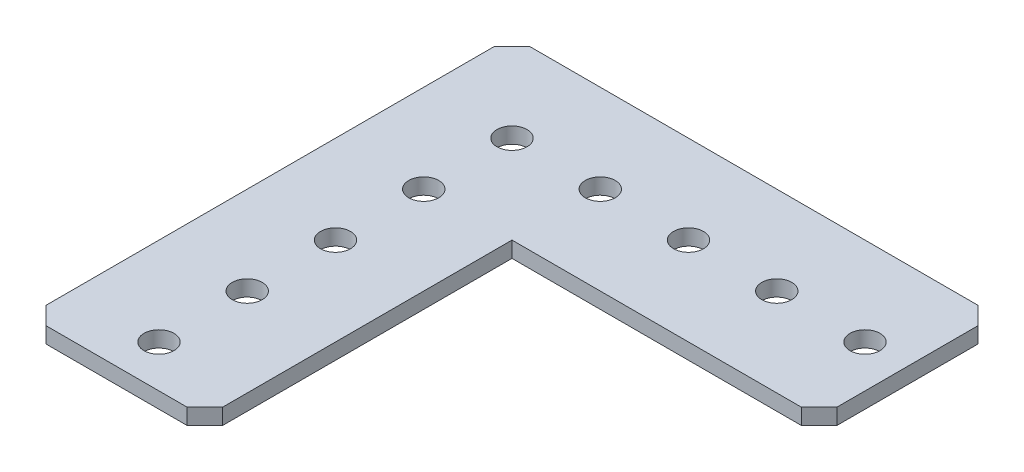
from build123d import *

# Parameters (mm, degrees)
SKETCH1_R           = 2.159
BOSS_EXTRUDE1_DEPTH = 2.286


with BuildPart() as part:
    # Sketch1 → Boss-Extrude1 (new body)
    with BuildSketch(Plane(origin=(0, 0, 0), x_dir=(1, 0, 0), z_dir=(0, 1, 0))):
        Polygon((0, 2.54), (0, 67.056), (2.54, 69.596), (67.056, 69.596), (69.596, 67.056), (69.596, 46.736), (67.056, 44.196), (25.4, 44.196), (25.4, 2.54), (22.86, 0), (2.54, 0), align=None)
        with Locations((12.7, 56.896)):
            Circle(SKETCH1_R, mode=Mode.SUBTRACT)
        with Locations((25.4, 56.896)):
            Circle(SKETCH1_R, mode=Mode.SUBTRACT)
        with Locations((38.1, 56.896)):
            Circle(SKETCH1_R, mode=Mode.SUBTRACT)
        with Locations((50.8, 56.896)):
            Circle(SKETCH1_R, mode=Mode.SUBTRACT)
        with Locations((63.5, 56.896)):
            Circle(SKETCH1_R, mode=Mode.SUBTRACT)
        with Locations((12.7, 44.196)):
            Circle(SKETCH1_R, mode=Mode.SUBTRACT)
        with Locations((12.7, 31.496)):
            Circle(SKETCH1_R, mode=Mode.SUBTRACT)
        with Locations((12.7, 18.796)):
            Circle(SKETCH1_R, mode=Mode.SUBTRACT)
        with Locations((12.7, 6.096)):
            Circle(SKETCH1_R, mode=Mode.SUBTRACT)
    extrude(amount=BOSS_EXTRUDE1_DEPTH)


solid = part.part
